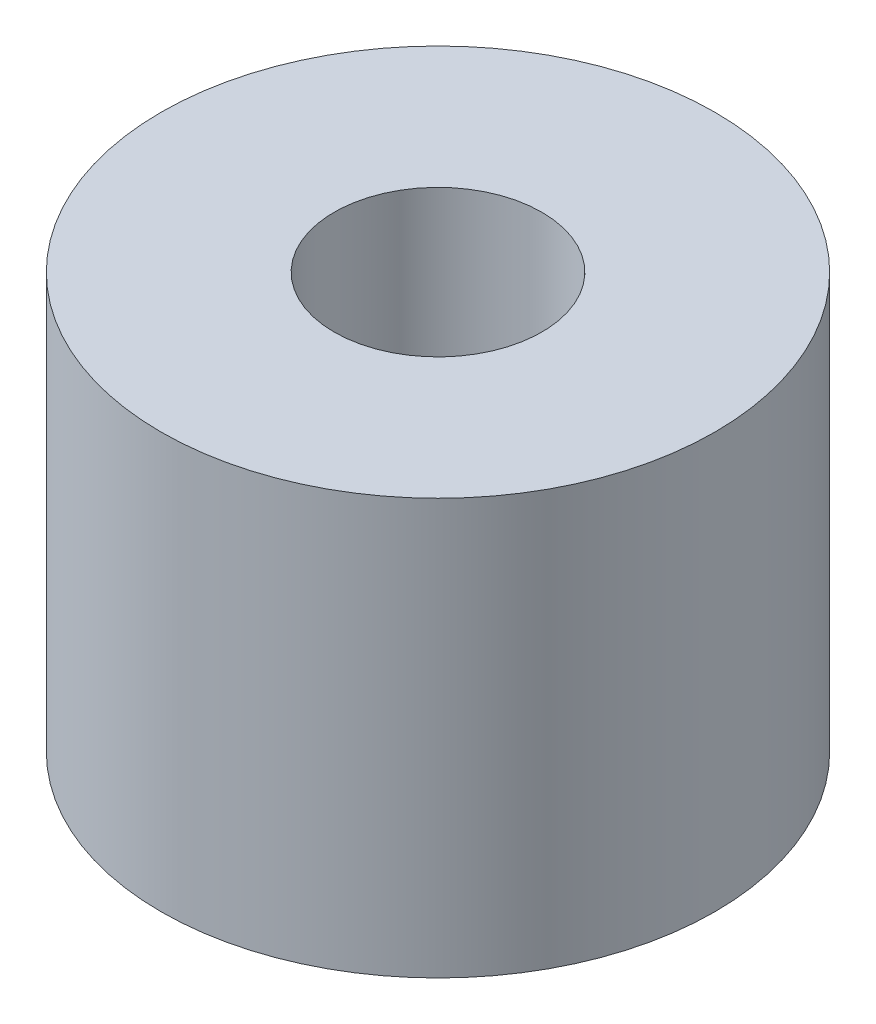
from build123d import *

# Parameters (mm, degrees)
SKETCH2_R           = 12.7
SKETCH2_R_2         = 4.7625
BOSS_EXTRUDE1_DEPTH = 19.05


with BuildPart() as part:
    # Sketch2 → Boss-Extrude1 (new body)
    with BuildSketch(Plane(origin=(0, 0, 0), x_dir=(1, 0, 0), z_dir=(0, 1, 0))):
        Circle(SKETCH2_R)
        Circle(SKETCH2_R_2, mode=Mode.SUBTRACT)
    extrude(amount=BOSS_EXTRUDE1_DEPTH)


solid = part.part
